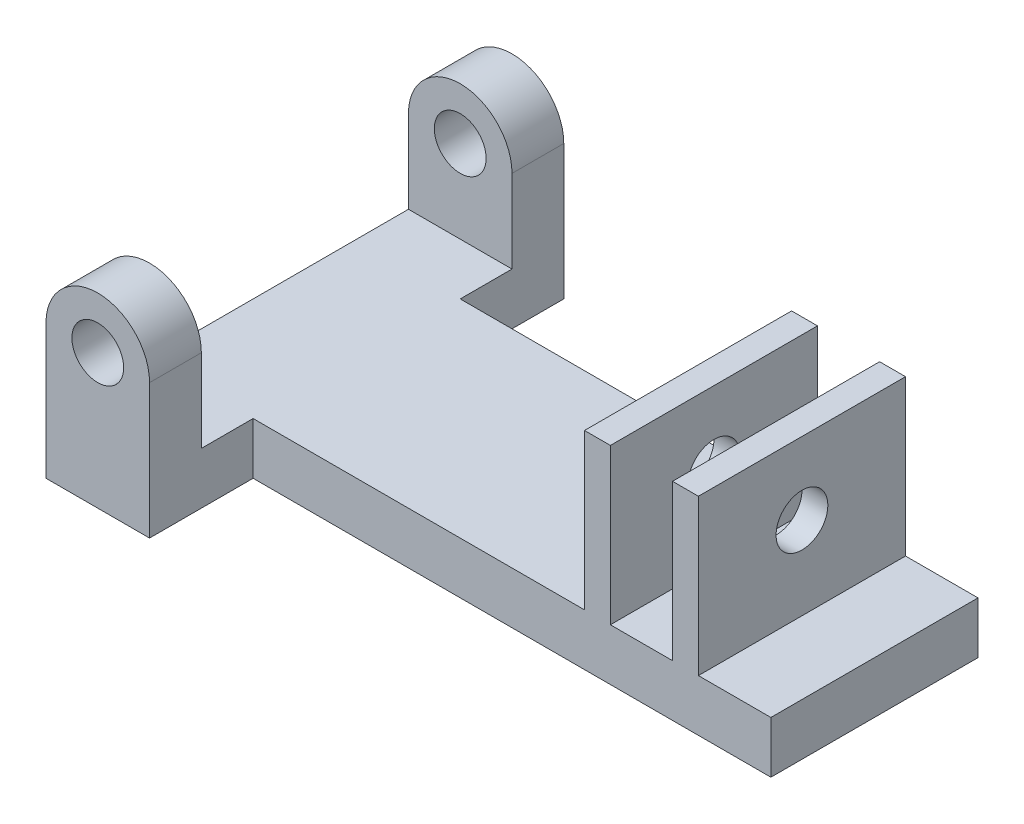
from build123d import *

# Parameters (mm, degrees)
SKETCH1_W                         = 12.7
SKETCH1_H                         = 50.8
BASE_EXTRUDE_DEPTH                = 6.35
SKETCH6_W                         = 12.7
SKETCH6_H                         = 6.35
ARCH_BASE_EXTRUDE_DEPTH           = 10.16
ARCH_EXTRUDE_DEPTH                = 6.35
SKETCH3_R                         = 3.175
ARCH_HOLE_CUT_DEPTH               = 6.35
SKETCH4_W                         = 25.4
SKETCH4_H                         = 6.35
TAB_EXTRUDE_DEPTH                 = 63.5
SKETCH5_W                         = 3.175
SKETCH5_H                         = 25.4
SQUARE_SLIDE_GUIDES_EXTRUDE_DEPTH = 19.05
SKETCH14_R                        = 3.175
CUT_EXTRUDE3_DEPTH                = 13.97


with BuildPart() as part:
    # Sketch1 → Base Extrude (new body)
    with BuildSketch(Plane(origin=(0, 0, 0), x_dir=(1, 0, 0), z_dir=(0, 1, 0))):
        with Locations((-6.35, 25.4)):
            Rectangle(SKETCH1_W, SKETCH1_H)
    extrude(amount=BASE_EXTRUDE_DEPTH)

    # Sketch6 → Arch Base Extrude (add)
    with BuildSketch(Plane(origin=(0, 6.35, 0), x_dir=(1, 0, 0), z_dir=(0, 1, 0))):
        with Locations((-6.35, 3.175)):
            Rectangle(SKETCH6_W, SKETCH6_H)
    arch_base_extrude = extrude(amount=ARCH_BASE_EXTRUDE_DEPTH)

    # Mirror Arch Base: Arch Base Extrude across plane
    add(arch_base_extrude.mirror(Plane.XY.offset(-25.4)))

    # Sketch2 → Arch Extrude (add)
    with BuildSketch(Plane.XY):
        with BuildLine():
            Line((-12.7, 16.51), (0, 16.51))
            ThreePointArc((0, 16.51), (-6.35, 22.86), (-12.7, 16.51))
        make_face()
    arch_extrude = extrude(amount=-ARCH_EXTRUDE_DEPTH)

    # Sketch3 → Arch Hole Cut (cut)
    with BuildSketch(Plane.XY):
        with Locations((-6.35, 16.51)):
            Circle(SKETCH3_R)
    arch_hole_cut = extrude(amount=-ARCH_HOLE_CUT_DEPTH, mode=Mode.SUBTRACT)

    # Mirror Arch and Hole: Arch Extrude, Arch Hole Cut across plane
    add(arch_extrude.mirror(Plane.XY.offset(-25.4)))
    add(arch_hole_cut.mirror(Plane.XY.offset(-25.4)), mode=Mode.SUBTRACT)

    # Sketch4 → Tab Extrude (add)
    with BuildSketch(Plane(origin=(0, 0, 0), x_dir=(0, 0, -1), z_dir=(1, 0, 0))):
        with Locations((25.4, 3.175)):
            Rectangle(SKETCH4_W, SKETCH4_H)
    extrude(amount=TAB_EXTRUDE_DEPTH)

    # Sketch5 → Square Slide Guides Extrude (add)
    with BuildSketch(Plane(origin=(0, 6.35, 0), x_dir=(1, 0, 0), z_dir=(0, 1, 0))):
        with Locations((42.2275, 25.4)):
            Rectangle(SKETCH5_W, SKETCH5_H)
        with Locations((53.0225, 25.4)):
            Rectangle(SKETCH5_W, SKETCH5_H)
    extrude(amount=SQUARE_SLIDE_GUIDES_EXTRUDE_DEPTH)

    # Sketch14 → Cut-Extrude3 (cut)
    with BuildSketch(Plane(origin=(54.61, 0, 0), x_dir=(0, 0, -1), z_dir=(1, 0, 0))):
        with Locations((25.4, 16.51)):
            Circle(SKETCH14_R)
    extrude(amount=-CUT_EXTRUDE3_DEPTH, mode=Mode.SUBTRACT)


solid = part.part
